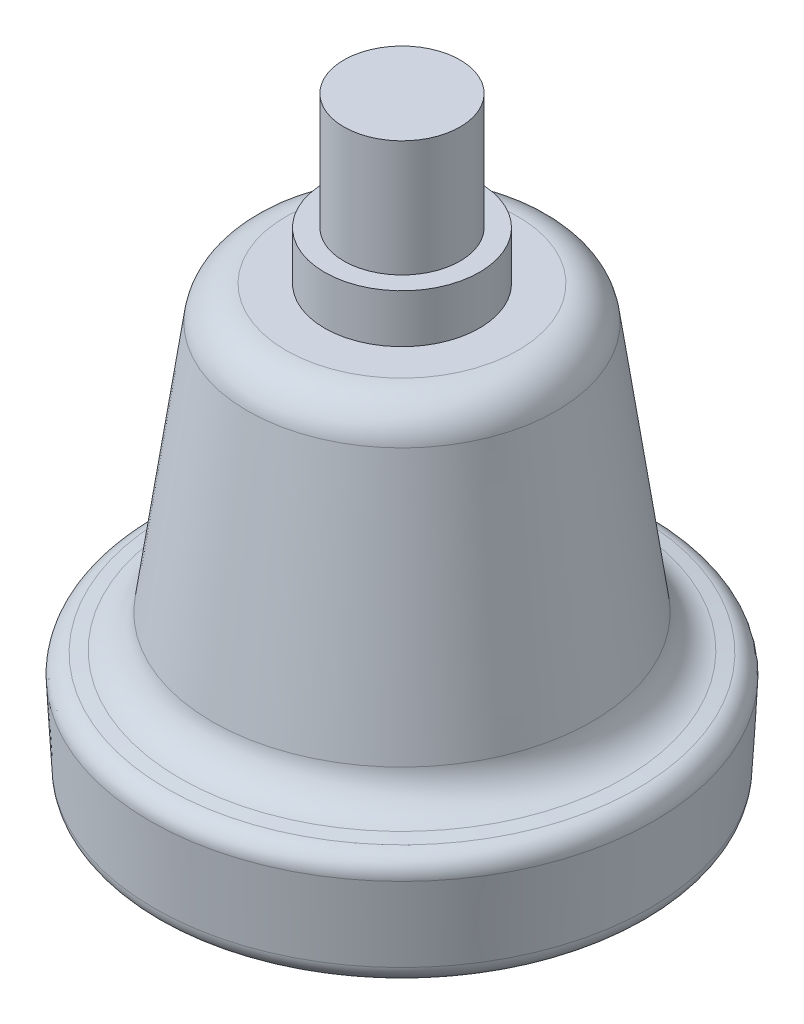
from build123d import *


with BuildPart() as part:
    # Esquisse1 → Révolution1 (revolve)
    with BuildSketch(Plane(origin=(0, 0, 0), x_dir=(0, 0, -1), z_dir=(1, 0, 0))):
        with BuildLine():
            Line((8, -5), (8, 0))
            Line((8, 0), (6, 0))
            Line((6, 0), (6, 12))
            Line((6, 12), (0, 12))
            Line((0, 12), (0, -50))
            Line((0, -50), (23.580737766, -50))
            ThreePointArc((23.580737766, -50), (24.957446917, -49.450748742), (25.577996835, -48.104671912))
            Line((25.577996835, -48.104671912), (25.99725907, -40.104671912))
            ThreePointArc((25.99725907, -40.104671912), (25.554291923, -38.741359218), (24.31286893, -38.024623319))
            Line((24.31286893, -38.024623319), (22.923403705, -37.804553647))
            ThreePointArc((22.923403705, -37.804553647), (20.696139769, -36.657437342), (19.58806929, -34.410492688))
            Line((19.58806929, -34.410492688), (15.938619423, -8.443307596))
            ThreePointArc((15.938619423, -8.443307596), (14.601783264, -5.981161679), (11.977547148, -5))
            Line((11.977547148, -5), (8, -5))
        make_face()
    revolve(axis=Axis((0, 12, 0), (0, -1, 0)))


solid = part.part
